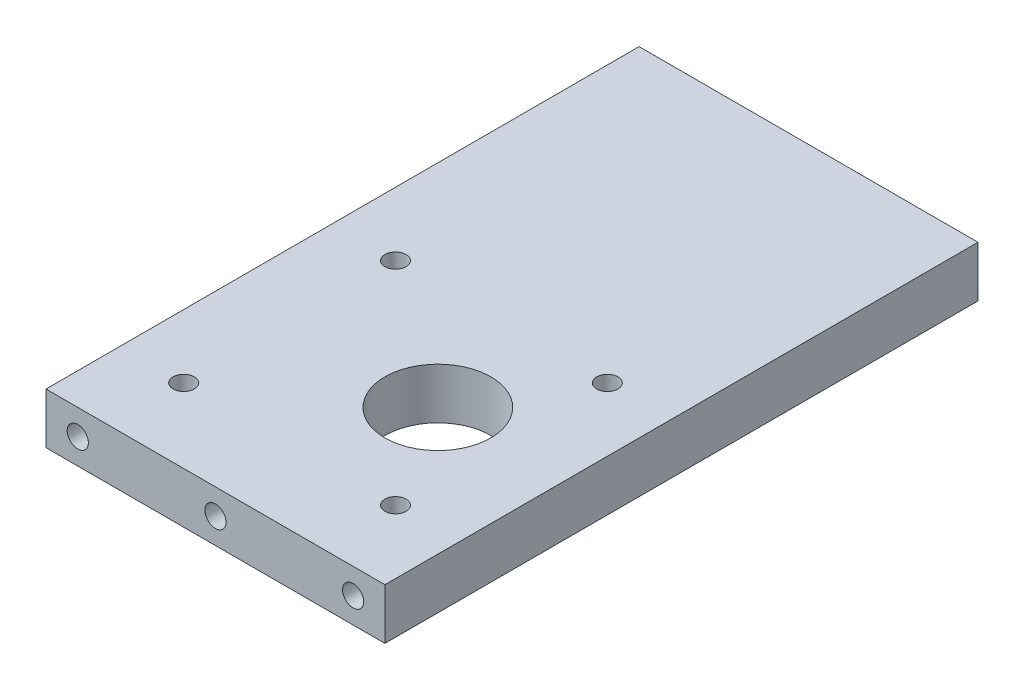
from build123d import *

# Parameters (mm, degrees)
SKETCH1_W                  = 80
SKETCH1_H                  = 140
SKETCH1_R                  = 12.5
BOSS_EXTRUDE1_DEPTH        = 6
M6_TAPPED_HOLE1_D          = 5
M6_TAPPED_HOLE2_AT_2_COUNT = 2
M6_TAPPED_HOLE2_AT_2_PITCH = 32.5
M6_TAPPED_HOLE2_AT_3_COUNT = 2
M6_TAPPED_HOLE2_AT_3_PITCH = 65
M8X1_0_TAPPED_HOLE1_D      = 7
M8X1_0_TAPPED_HOLE1_DEPTH  = 19
M8X1_0_TAPPED_HOLE1_TIP    = 2.103012167


with BuildPart() as part:
    # Sketch1 → Boss-Extrude1 (new body, symmetric)
    with BuildSketch(Plane(origin=(0, 0, 0), x_dir=(1, 0, 0), z_dir=(0, 1, 0))):
        with Locations((0, 70)):
            Rectangle(SKETCH1_W, SKETCH1_H)
        with Locations((10, 42.5)):
            Circle(SKETCH1_R, mode=Mode.SUBTRACT)
    extrude(amount=BOSS_EXTRUDE1_DEPTH, both=True)

    # M6 Tapped Hole1 (through all)
    with Locations(Plane(origin=(0, 6, 0), x_dir=(1, 0, 0), z_dir=(0, 1, 0))):
        with Locations((-25, 67.5), (25, 67.5), (25, 17.5), (-25, 17.5)):
            Hole(M6_TAPPED_HOLE1_D / 2)

    # Sketch9 → M6 Tapped Hole2 (revolve, cut)
    with BuildSketch(Plane(origin=(32.5, 0, 0), x_dir=(0, -1, 0), z_dir=(1, 0, 0))):
        Polygon((0, 0), (0, 14.502151548), (2.5, 13), (2.5, 0), align=None)
    m6_tapped_hole2 = revolve(axis=Axis((32.5, 0, 6.35), (0, 0, -1)), mode=Mode.SUBTRACT)

    # M6 Tapped Hole2 at 2: M6 Tapped Hole2 ×2
    with Locations(*[(-i * M6_TAPPED_HOLE2_AT_2_PITCH, 0, 0) for i in range(1, M6_TAPPED_HOLE2_AT_2_COUNT)]):
        add(m6_tapped_hole2, mode=Mode.SUBTRACT)

    # M6 Tapped Hole2 at 3: M6 Tapped Hole2 ×2
    with Locations(*[(-i * M6_TAPPED_HOLE2_AT_3_PITCH, 0, 0) for i in range(1, M6_TAPPED_HOLE2_AT_3_COUNT)]):
        add(m6_tapped_hole2, mode=Mode.SUBTRACT)

    # Mirror1: M6 Tapped Hole2 across plane
    add(m6_tapped_hole2.mirror(Plane(origin=(0, 0, -70), x_dir=(1, 0, 0), z_dir=(0, 0, -1))), mode=Mode.SUBTRACT)

    # Mirror1 copy 1 sketch → Mirror1 copy 1 (revolve, cut)
    with BuildSketch(Plane(origin=(0, 0, -140), x_dir=(0, -1, 0), z_dir=(1, 0, 0))):
        Polygon((0, 0), (0, -14.502151548), (2.5, -13), (2.5, 0), align=None)
    revolve(axis=Axis((0, 0, -146.35), (0, 0, -1)), mode=Mode.SUBTRACT)

    # Mirror1 copy 2 sketch → Mirror1 copy 2 (revolve, cut)
    with BuildSketch(Plane(origin=(-32.5, 0, -140), x_dir=(0, -1, 0), z_dir=(1, 0, 0))):
        Polygon((0, 0), (0, -14.502151548), (2.5, -13), (2.5, 0), align=None)
    revolve(axis=Axis((-32.5, 0, -146.35), (0, 0, -1)), mode=Mode.SUBTRACT)

    # M8x1.0 Tapped Hole1
    with Locations(Plane.ZY.offset(40)):
        with Locations((-113, 0), (-86, 0)):
            Hole(M8X1_0_TAPPED_HOLE1_D / 2, depth=M8X1_0_TAPPED_HOLE1_DEPTH)
            with Locations((0, 0, -(M8X1_0_TAPPED_HOLE1_DEPTH + M8X1_0_TAPPED_HOLE1_TIP / 2))):  # 118° drill point
                Cone(0, M8X1_0_TAPPED_HOLE1_D / 2, M8X1_0_TAPPED_HOLE1_TIP, mode=Mode.SUBTRACT)


solid = part.part
